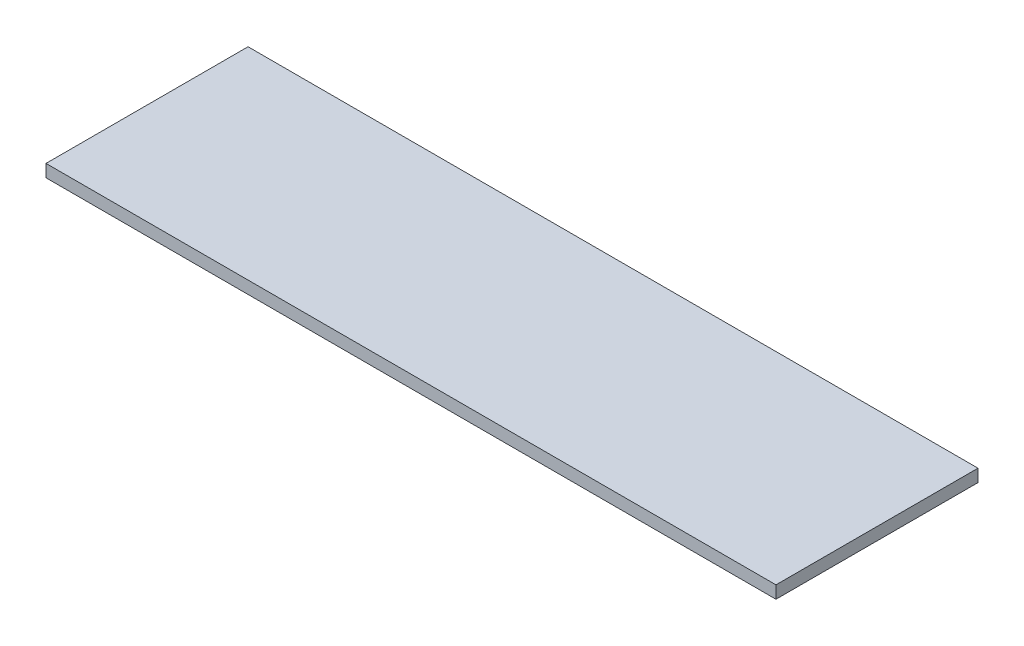
from build123d import *

# Parameters (mm, degrees)
SKETCH1_W           = 1066.8
SKETCH1_H           = 295.275
BOSS_EXTRUDE1_DEPTH = 18.25625


with BuildPart() as part:
    # Sketch1 → Boss-Extrude1 (new body)
    with BuildSketch(Plane(origin=(0, 0, 0), x_dir=(1, 0, 0), z_dir=(0, 1, 0))):
        Rectangle(SKETCH1_W, SKETCH1_H)
    extrude(amount=BOSS_EXTRUDE1_DEPTH)


solid = part.part
